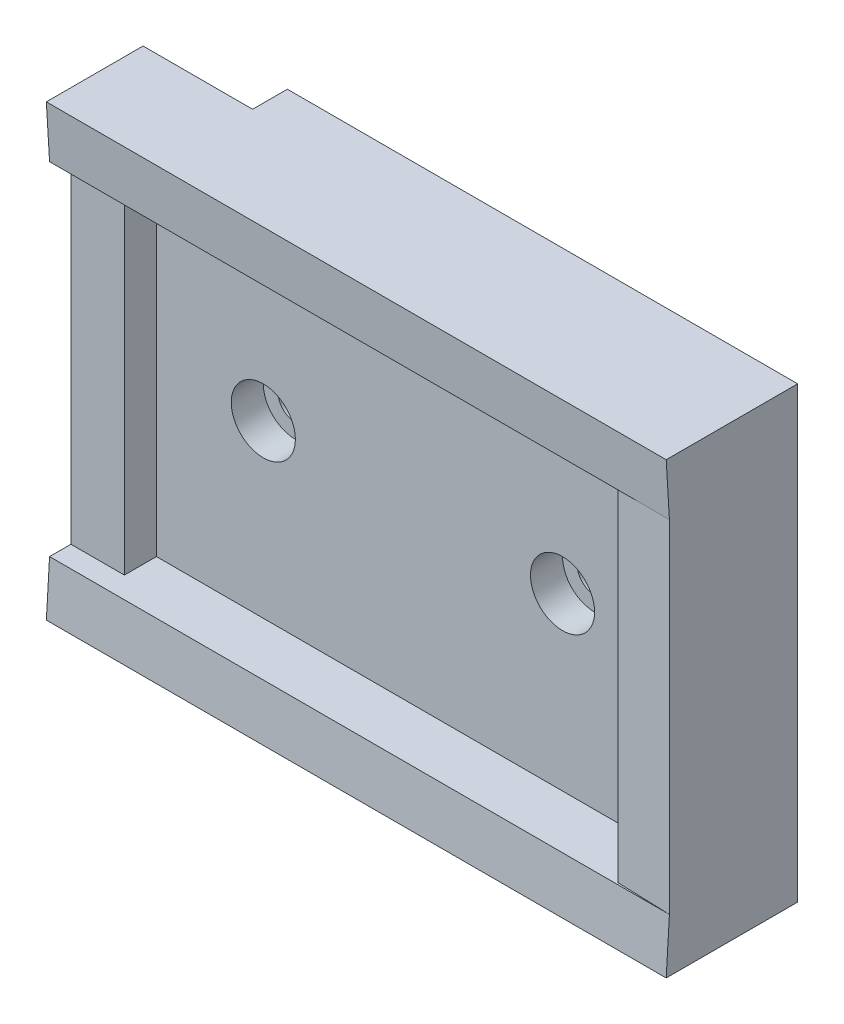
from build123d import *

# Parameters (mm, degrees)
ESQUISSE1_W                  = 58
ESQUISSE1_H                  = 32
BOSS_EXTRU_1_DEPTH           = 7
ESQUISSE2_W                  = 5
ESQUISSE2_H                  = 32
BOSS_EXTRU_3_DEPTH           = 3
ESQUISSE3_W                  = 5
ESQUISSE3_H                  = 32
BOSS_EXTRU_4_DEPTH           = 5
ENL_V_MAT_EXTRU_1_DEPTH      = 33
ESQUISSE6_R                  = 1.625
ENL_V_MAT_EXTRU_2_DEPTH      = 8
ESQUISSE8_R                  = 3
ENL_V_MAT_EXTRU_4_DEPTH      = 3
ESQUISSE7_W                  = 10.25
ESQUISSE7_H                  = 3.25
ENL_V_MAT_EXTRU_3_DEPTH      = 10
ENL_V_MAT_EXTRU_3_DEPTH_BACK = 50
ESQUISSE9_W                  = 58
ESQUISSE9_H                  = 5
BOSS_EXTRU_5_DEPTH           = 12
BOSS_EXTRU_6_DEPTH           = 58
ESQUISSE12_W                 = 10.25
ESQUISSE12_H                 = 5
ENL_V_MAT_EXTRU_5_DEPTH      = 3.25


with BuildPart() as part:
    # Esquisse1 → Boss.-Extru.1 (new body)
    with BuildSketch(Plane.XY):
        with Locations((29, -16)):
            Rectangle(ESQUISSE1_W, ESQUISSE1_H)
    extrude(amount=BOSS_EXTRU_1_DEPTH)

    # Esquisse2 → Boss.-Extru.3 (add)
    with BuildSketch(Plane.XY.offset(7)):
        with Locations((2.5, -16)):
            Rectangle(ESQUISSE2_W, ESQUISSE2_H)
    extrude(amount=BOSS_EXTRU_3_DEPTH)

    # Esquisse3 → Boss.-Extru.4 (add)
    with BuildSketch(Plane.XY.offset(7)):
        with Locations((55.5, -16)):
            Rectangle(ESQUISSE3_W, ESQUISSE3_H)
    extrude(amount=BOSS_EXTRU_4_DEPTH)

    # Esquisse4 → Enlèv. mat.-Extru.1 (cut, through all)
    with BuildSketch(Plane.XZ.offset(32)):
        Polygon((0, 10), (58, 12), (0, 12), align=None)
    extrude(amount=-ENL_V_MAT_EXTRU_1_DEPTH, mode=Mode.SUBTRACT)

    # Esquisse6 → Enlèv. mat.-Extru.2 (cut, through all)
    with BuildSketch(Plane.XY.offset(7)):
        with Locations((43, -16)):
            Circle(ESQUISSE6_R)
        with Locations((15, -16)):
            Circle(ESQUISSE6_R)
    extrude(amount=-ENL_V_MAT_EXTRU_2_DEPTH, mode=Mode.SUBTRACT)

    # Esquisse8 → Enlèv. mat.-Extru.4 (cut)
    with BuildSketch(Plane.XY.offset(7)):
        with Locations((15, -16)):
            Circle(ESQUISSE8_R)
        with Locations((43, -16)):
            Circle(ESQUISSE8_R)
    extrude(amount=-ENL_V_MAT_EXTRU_4_DEPTH, mode=Mode.SUBTRACT)

    # Esquisse7 → Enlèv. mat.-Extru.3 (cut, two sides)
    with BuildSketch(Plane.XZ.offset(32)) as enl_v_mat_extru_3_sk:
        with Locations((5.125, 1.625)):
            Rectangle(ESQUISSE7_W, ESQUISSE7_H)
    extrude(amount=ENL_V_MAT_EXTRU_3_DEPTH, mode=Mode.SUBTRACT)
    extrude(enl_v_mat_extru_3_sk.sketch, amount=-ENL_V_MAT_EXTRU_3_DEPTH_BACK, mode=Mode.SUBTRACT)

    # Esquisse9 → Boss.-Extru.5 (add)
    with BuildSketch(Plane.XY):
        with Locations((29, 2.5)):
            Rectangle(ESQUISSE9_W, ESQUISSE9_H)
        with Locations((29, -34.5)):
            Rectangle(ESQUISSE9_W, ESQUISSE9_H)
    extrude(amount=BOSS_EXTRU_5_DEPTH)

    # Esquisse10 → Boss.-Extru.6 (add, through all)
    with BuildSketch(Plane.ZY):
        Polygon((12, 5), (12.3, 5), (12, 0), align=None)
        Polygon((12, -32), (12, -37), (12.3, -37), align=None)
    extrude(amount=-BOSS_EXTRU_6_DEPTH)

    # Esquisse12 → Enlèv. mat.-Extru.5 (cut)
    with BuildSketch(Plane(origin=(0, 0, 0), x_dir=(-1, 0, 0), z_dir=(0, 0, -1))):
        with Locations((-5.125, -34.5)):
            Rectangle(ESQUISSE12_W, ESQUISSE12_H)
        with Locations((-5.125, 2.5)):
            Rectangle(ESQUISSE12_W, ESQUISSE12_H)
    extrude(amount=-ENL_V_MAT_EXTRU_5_DEPTH, mode=Mode.SUBTRACT)


solid = part.part
